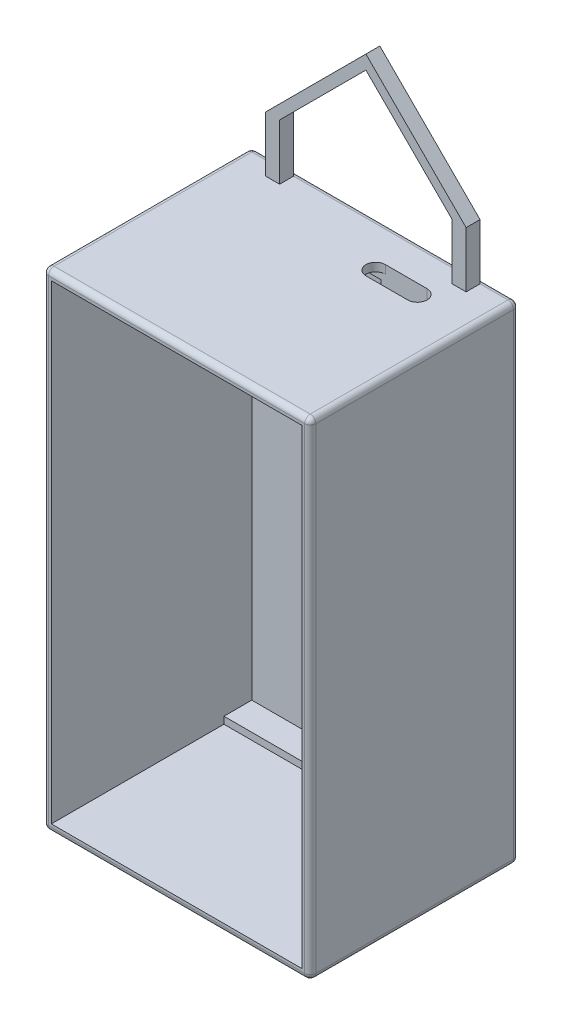
from build123d import *

# Parameters (mm, degrees)
SKETCH1_W           = 96
SKETCH1_H           = 175
BOSS_EXTRUDE1_DEPTH = 100
SKETCH2_W           = 90
SKETCH2_H           = 169
CUT_EXTRUDE1_DEPTH  = 87
SKETCH3_W           = 56.5
SKETCH3_H           = 164
CUT_EXTRUDE2_DEPTH  = 10
SKETCH5_R           = 6
CUT_EXTRUDE3_DEPTH  = 10
SKETCH6_W           = 33.5
SKETCH6_H           = 48
CUT_EXTRUDE4_DEPTH  = 10
CUT_EXTRUDE6_DEPTH  = 10
SKETCH10_W          = 96
SKETCH10_H          = 25
CUT_EXTRUDE8_DEPTH  = 200
FILLET1_R           = 2
SKETCH11_R          = 2.5
CUT_EXTRUDE9_DEPTH  = 5
SKETCH12_W          = 5
SKETCH12_H          = 5
BOSS_EXTRUDE2_DEPTH = 20
BOSS_EXTRUDE5_DEPTH = 5


with BuildPart() as part:
    # Sketch1 → Boss-Extrude1 (new body)
    with BuildSketch(Plane.XY):
        Rectangle(SKETCH1_W, SKETCH1_H)
    extrude(amount=BOSS_EXTRUDE1_DEPTH)

    # Sketch2 → Cut-Extrude1 (cut)
    with BuildSketch(Plane.XY.offset(100)):
        Rectangle(SKETCH2_W, SKETCH2_H)
    extrude(amount=-CUT_EXTRUDE1_DEPTH, mode=Mode.SUBTRACT)

    # Sketch3 → Cut-Extrude2 (cut)
    with BuildSketch(Plane.XY.offset(13)):
        with Locations((-16.75, 0)):
            Rectangle(SKETCH3_W, SKETCH3_H)
    extrude(amount=-CUT_EXTRUDE2_DEPTH, mode=Mode.SUBTRACT)

    # Sketch5 → Cut-Extrude3 (cut)
    with BuildSketch(Plane(origin=(0, -84.5, 0), x_dir=(1, 0, 0), z_dir=(0, 1, 0))):
        with Locations((28.25, -23)):
            Circle(SKETCH5_R)
    extrude(amount=-CUT_EXTRUDE3_DEPTH, mode=Mode.SUBTRACT)

    # Sketch6 → Cut-Extrude4 (cut)
    with BuildSketch(Plane.XY.offset(13)):
        with Locations((28.25, -15.5)):
            Rectangle(SKETCH6_W, SKETCH6_H)
    extrude(amount=-CUT_EXTRUDE4_DEPTH, mode=Mode.SUBTRACT)

    # Sketch9 → Cut-Extrude6 (cut)
    with BuildSketch(Plane.XZ.offset(-84.5)):
        with BuildLine():
            Line((13, 20), (28, 20))
            ThreePointArc((28, 20), (31.5, 16.5), (28, 13))
            Line((28, 13), (13, 13))
            ThreePointArc((13, 13), (9.5, 16.5), (13, 20))
        make_face()
    extrude(amount=-CUT_EXTRUDE6_DEPTH, mode=Mode.SUBTRACT)

    # Sketch10 → Cut-Extrude8 (cut)
    with BuildSketch(Plane.XZ.offset(87.5)):
        with Locations((0, 87.5)):
            Rectangle(SKETCH10_W, SKETCH10_H)
    extrude(amount=-CUT_EXTRUDE8_DEPTH, mode=Mode.SUBTRACT)

    # Fillet1
    fillet1_edges = [part.edges().sort_by_distance(p)[0] for p in [
        (0, 87.5, 0),
        (48, 0, 0),
        (0, -87.5, 0),
        (-48, 0, 0),
        (-48, 87.5, 37.5),
        (48, 87.5, 37.5),
        (48, -87.5, 37.5),
        (-48, -87.5, 37.5),
        (-48, 0, 75),
        (0, 87.5, 75),
        (48, 0, 75),
        (0, -87.5, 75),
    ]]
    fillet(fillet1_edges, radius=FILLET1_R)

    # Sketch11 → Cut-Extrude9 (cut)
    with BuildSketch(Plane.XZ.offset(87.5)):
        with Locations((0, 23)):
            Circle(SKETCH11_R)
    extrude(amount=-CUT_EXTRUDE9_DEPTH, mode=Mode.SUBTRACT)

    # Sketch12 → Boss-Extrude2 (add)
    with BuildSketch(Plane(origin=(0, 87.5, 0), x_dir=(1, 0, 0), z_dir=(0, 1, 0))):
        with Locations((-33.5, -4.5)):
            Rectangle(SKETCH12_W, SKETCH12_H)
        with Locations((33.5, -4.5)):
            Rectangle(SKETCH12_W, SKETCH12_H)
    extrude(amount=BOSS_EXTRUDE2_DEPTH)

    # Sketch15 → Boss-Extrude5 (add)
    with BuildSketch(Plane.XY.offset(7)):
        Polygon((-31, 107.5), (0, 138.5), (31, 107.5), (36, 107.5), (0, 143.5), (-36, 107.5), align=None)
    extrude(amount=-BOSS_EXTRUDE5_DEPTH)


solid = part.part
